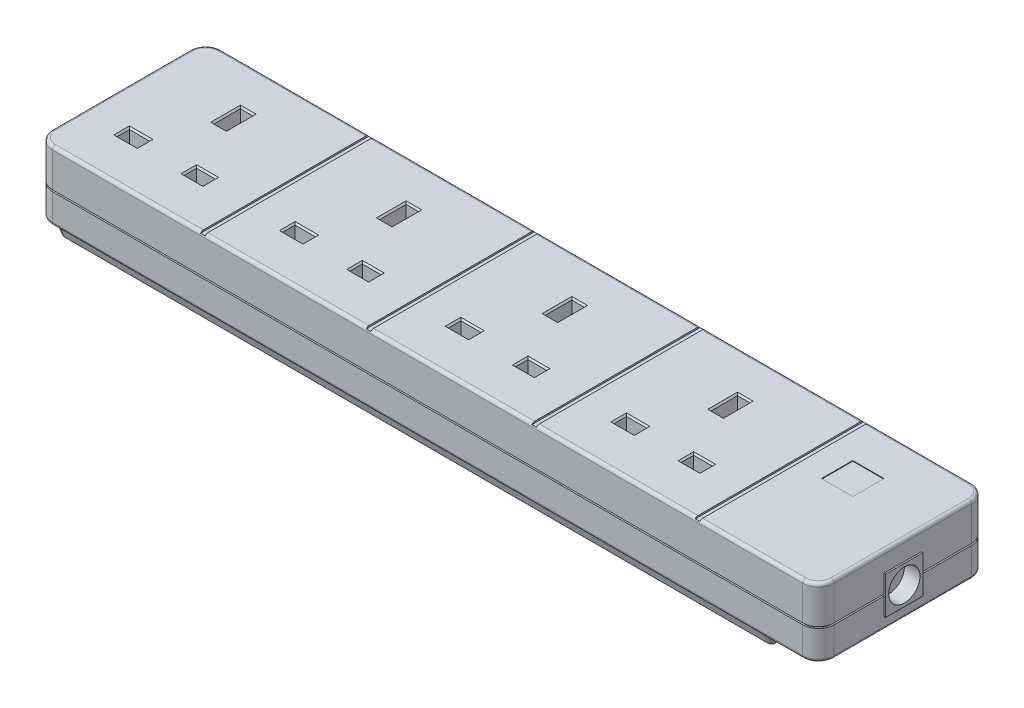
from build123d import *

# Parameters (mm, degrees)
BOSS_EXTRUDE1_DEPTH        = 12
BOSS_EXTRUDE2_DEPTH        = 0.5
BOSS_EXTRUDE3_DEPTH        = 9.5
BOSS_EXTRUDE4_DEPTH        = 5
BOSS_EXTRUDE4_TAPER        = 20
FILLET1_R                  = 1
SKETCH5_W                  = 1.5
SKETCH5_H                  = 54
CUT_EXTRUDE1_DEPTH         = 0.5
SKETCH6_W                  = 10
SKETCH6_H                  = 10
CUT_EXTRUDE2_DEPTH         = 2
SKETCH7_W                  = 8
SKETCH7_H                  = 8
CUT_EXTRUDE3_DEPTH         = 10
SKETCH8_W                  = 9.8
SKETCH8_H                  = 9.8
BOSS_EXTRUDE5_DEPTH        = 1.9
SKETCH9_W                  = 4
SKETCH9_H                  = 8.5
SKETCH9_W_2                = 6.5
SKETCH9_H_2                = 4
SKETCH9_W_3                = 6
CUT_EXTRUDE4_DEPTH         = 10
CHAMFER1_SIZE              = 0.5
LPATTERN1_COUNT            = 4
LPATTERN1_PITCH            = 53
CHAMFER1_OF_LPATTERN1_SIZE = 0.5
SKETCH10_W                 = 12
SKETCH10_H                 = 12
SKETCH10_R                 = 5
BOSS_EXTRUDE6_DEPTH        = 0.5
BOSS_EXTRUDE6_DEPTH_BACK   = 5
SKETCH11_R                 = 5
CUT_EXTRUDE5_DEPTH         = 5
CUT_EXTRUDE6_DEPTH         = 5
CUT_EXTRUDE7_DEPTH         = 3.5


with BuildPart() as part:
    # Sketch1 → Boss-Extrude1 (new body)
    with BuildSketch(Plane(origin=(0, 0, 0), x_dir=(1, 0, 0), z_dir=(0, 1, 0))):
        with BuildLine():
            Line((-120, 27), (120, 27))
            ThreePointArc((120, 27), (123.535533906, 25.535533906), (125, 22))
            Line((125, 22), (125, -22))
            ThreePointArc((125, -22), (123.535533906, -25.535533906), (120, -27))
            Line((120, -27), (-120, -27))
            ThreePointArc((-120, -27), (-123.535533906, -25.535533906), (-125, -22))
            Line((-125, -22), (-125, 22))
            ThreePointArc((-125, 22), (-123.535533906, 25.535533906), (-120, 27))
        make_face()
    extrude(amount=-BOSS_EXTRUDE1_DEPTH)

    # Sketch2 → Boss-Extrude2 (add)
    with BuildSketch(Plane.XZ.offset(12)):
        with BuildLine():
            Line((120, 26.5), (-120, 26.5))
            ThreePointArc((-120, 26.5), (-123.181980515, 25.181980515), (-124.5, 22))
            Line((-124.5, 22), (-124.5, -22))
            ThreePointArc((-124.5, -22), (-123.181980515, -25.181980515), (-120, -26.5))
            Line((-120, -26.5), (120, -26.5))
            ThreePointArc((120, -26.5), (123.181980515, -25.181980515), (124.5, -22))
            Line((124.5, -22), (124.5, 22))
            ThreePointArc((124.5, 22), (123.181980515, 25.181980515), (120, 26.5))
        make_face()
    extrude(amount=BOSS_EXTRUDE2_DEPTH)

    # Sketch3 → Boss-Extrude3 (add)
    with BuildSketch(Plane.XZ.offset(12.5)):
        with BuildLine():
            Line((125, 22), (125, -22))
            ThreePointArc((125, -22), (123.535533906, -25.535533906), (120, -27))
            Line((120, -27), (-120, -27))
            ThreePointArc((-120, -27), (-123.535533906, -25.535533906), (-125, -22))
            Line((-125, -22), (-125, 22))
            ThreePointArc((-125, 22), (-123.535533906, 25.535533906), (-120, 27))
            Line((-120, 27), (120, 27))
            ThreePointArc((120, 27), (123.535533906, 25.535533906), (125, 22))
        make_face()
    extrude(amount=BOSS_EXTRUDE3_DEPTH)

    # Sketch4 → Boss-Extrude4 (add)
    with BuildSketch(Plane.XZ.offset(22)):
        with BuildLine():
            Line((108, -22), (108, 22))
            ThreePointArc((108, 22), (107.121320344, 24.121320344), (105, 25))
            Line((105, 25), (-120, 25))
            ThreePointArc((-120, 25), (-122.121320344, 24.121320344), (-123, 22))
            Line((-123, 22), (-123, -22))
            ThreePointArc((-123, -22), (-122.121320344, -24.121320344), (-120, -25))
            Line((-120, -25), (105, -25))
            ThreePointArc((105, -25), (107.121320344, -24.121320344), (108, -22))
        make_face()
    extrude(amount=BOSS_EXTRUDE4_DEPTH, taper=BOSS_EXTRUDE4_TAPER)

    # Fillet1
    fillet1_edges = [part.edges().sort_by_distance(p)[0] for p in [
        (0, 0, -27),
        (123.535533906, 0, -25.535533906),
        (125, 0, 0),
        (123.535533906, 0, 25.535533906),
        (123.535533906, -22, -25.535533906),
        (125, -22, 0),
        (123.535533906, -22, 25.535533906),
        (0, -22, 27),
        (-123.535533906, -22, 25.535533906),
        (-125, -22, 0),
        (-123.535533906, -22, -25.535533906),
        (0, -22, -27),
        (0, 0, 27),
        (-123.535533906, 0, 25.535533906),
        (-125, 0, 0),
        (-123.535533906, 0, -25.535533906),
    ]]
    fillet(fillet1_edges, radius=FILLET1_R)

    # Sketch5 → Cut-Extrude1 (cut)
    with BuildSketch(Plane(origin=(0, 0, 0), x_dir=(1, 0, 0), z_dir=(0, 1, 0))):
        with Locations((-72, 0)):
            Rectangle(SKETCH5_W, SKETCH5_H)
        with Locations((-19, 0)):
            Rectangle(SKETCH5_W, SKETCH5_H)
        with Locations((34, 0)):
            Rectangle(SKETCH5_W, SKETCH5_H)
        with Locations((86.25, 0)):
            Rectangle(SKETCH5_W, SKETCH5_H)
    extrude(amount=-CUT_EXTRUDE1_DEPTH, mode=Mode.SUBTRACT)

    # Sketch6 → Cut-Extrude2 (cut)
    with BuildSketch(Plane(origin=(0, 0, 0), x_dir=(1, 0, 0), z_dir=(0, 1, 0))):
        with Locations((100, 9)):
            Rectangle(SKETCH6_W, SKETCH6_H)
    extrude(amount=-CUT_EXTRUDE2_DEPTH, mode=Mode.SUBTRACT)

    # Sketch7 → Cut-Extrude3 (cut)
    with BuildSketch(Plane(origin=(0, -2, 0), x_dir=(1, 0, 0), z_dir=(0, 1, 0))):
        with Locations((100, 9)):
            Rectangle(SKETCH7_W, SKETCH7_H)
    extrude(amount=-CUT_EXTRUDE3_DEPTH, mode=Mode.SUBTRACT)

    # Sketch9 → Cut-Extrude4 (cut)
    with BuildSketch(Plane(origin=(0, 0, 0), x_dir=(1, 0, 0), z_dir=(0, 1, 0))):
        with Locations((60.125, 9.75)):
            Rectangle(SKETCH9_W, SKETCH9_H)
        with Locations((49.375, -11.5)):
            Rectangle(SKETCH9_W_2, SKETCH9_H_2)
        with Locations((70.625, -11.5)):
            Rectangle(SKETCH9_W_3, SKETCH9_H_2)
    cut_extrude4 = extrude(amount=-CUT_EXTRUDE4_DEPTH, mode=Mode.SUBTRACT)

    # Chamfer1
    chamfer1_edges = [part.edges().sort_by_distance(p)[0] for p in [
        (58.125, 0, -9.75),
        (60.125, 0, -5.5),
        (62.125, 0, -9.75),
        (60.125, 0, -14),
        (46.125, 0, 11.5),
        (49.375, 0, 13.5),
        (52.625, 0, 11.5),
        (49.375, 0, 9.5),
        (67.625, 0, 11.5),
        (70.625, 0, 13.5),
        (73.625, 0, 11.5),
        (70.625, 0, 9.5),
    ]]
    chamfer(chamfer1_edges, length=CHAMFER1_SIZE)

    # LPattern1: Cut-Extrude4 ×4
    with Locations(*[(-i * LPATTERN1_PITCH, 0, 0) for i in range(1, LPATTERN1_COUNT)]):
        add(cut_extrude4, mode=Mode.SUBTRACT)

    # Chamfer1 of LPattern1
    chamfer1_of_lpattern1_edges = [part.edges().sort_by_distance(p)[0] for p in [
        (5.125, 0, -9.75),
        (7.125, 0, -5.5),
        (9.125, 0, -9.75),
        (7.125, 0, -14),
        (-6.875, 0, 11.5),
        (-3.625, 0, 13.5),
        (-0.375, 0, 11.5),
        (-3.625, 0, 9.5),
        (14.625, 0, 11.5),
        (17.625, 0, 13.5),
        (20.625, 0, 11.5),
        (17.625, 0, 9.5),
        (-47.875, 0, -9.75),
        (-45.875, 0, -5.5),
        (-43.875, 0, -9.75),
        (-45.875, 0, -14),
        (-59.875, 0, 11.5),
        (-56.625, 0, 13.5),
        (-53.375, 0, 11.5),
        (-56.625, 0, 9.5),
        (-38.375, 0, 11.5),
        (-35.375, 0, 13.5),
        (-32.375, 0, 11.5),
        (-35.375, 0, 9.5),
        (-100.875, 0, -9.75),
        (-98.875, 0, -5.5),
        (-96.875, 0, -9.75),
        (-98.875, 0, -14),
        (-112.875, 0, 11.5),
        (-109.625, 0, 13.5),
        (-106.375, 0, 11.5),
        (-109.625, 0, 9.5),
        (-91.375, 0, 11.5),
        (-88.375, 0, 13.5),
        (-85.375, 0, 11.5),
        (-88.375, 0, 9.5),
    ]]
    chamfer(chamfer1_of_lpattern1_edges, length=CHAMFER1_OF_LPATTERN1_SIZE)

    # Sketch10 → Boss-Extrude6 (add, two sides)
    with BuildSketch(Plane(origin=(125, 0, 0), x_dir=(0, 0, -1), z_dir=(1, 0, 0))) as boss_extrude6_sk:
        with Locations((0, -12.25)):
            Rectangle(SKETCH10_W, SKETCH10_H)
        with Locations((0, -12.25)):
            Circle(SKETCH10_R, mode=Mode.SUBTRACT)
    extrude(amount=BOSS_EXTRUDE6_DEPTH)
    extrude(boss_extrude6_sk.sketch, amount=-BOSS_EXTRUDE6_DEPTH_BACK)

    # Sketch11 → Cut-Extrude5 (cut)
    with BuildSketch(Plane(origin=(125.5, 0, 0), x_dir=(0, 0, -1), z_dir=(1, 0, 0))):
        with Locations((0, -12.25)):
            Circle(SKETCH11_R)
    extrude(amount=-CUT_EXTRUDE5_DEPTH, mode=Mode.SUBTRACT)

    # Sketch12 → Cut-Extrude6 (cut)
    with BuildSketch(Plane.XZ.offset(27)):
        with BuildLine():
            Line((-77.5, -5.436931771), (-77.5, -9))
            ThreePointArc((-77.5, -9), (-80, -11.5), (-82.5, -9))
            Line((-82.5, -9), (-82.5, -5.436931771))
            ThreePointArc((-82.5, -5.436931771), (-80, 2.25), (-77.5, -5.436931771))
        make_face()
        with BuildLine():
            Line((71.5, -9), (71.5, -5.436931771))
            ThreePointArc((71.5, -5.436931771), (74, 2.25), (76.5, -5.436931771))
            Line((76.5, -5.436931771), (76.5, -9))
            ThreePointArc((76.5, -9), (74, -11.5), (71.5, -9))
        make_face()
    extrude(amount=-CUT_EXTRUDE6_DEPTH, mode=Mode.SUBTRACT)

    # Sketch13 → Cut-Extrude7 (cut)
    with BuildSketch(Plane.XZ.offset(22)):
        with BuildLine():
            Line((-75.75, -2), (-75.75, -9))
            ThreePointArc((-75.75, -9), (-80, -13.25), (-84.25, -9))
            Line((-84.25, -9), (-84.25, -2))
            ThreePointArc((-84.25, -2), (-80, 2.25), (-75.75, -2))
        make_face()
        with BuildLine():
            Line((78.25, -2), (78.25, -9))
            ThreePointArc((78.25, -9), (74, -13.25), (69.75, -9))
            Line((69.75, -9), (69.75, -2))
            ThreePointArc((69.75, -2), (74, 2.25), (78.25, -2))
        make_face()
    extrude(amount=CUT_EXTRUDE7_DEPTH, mode=Mode.SUBTRACT)


with BuildPart() as body_2:
    # Sketch8 → Boss-Extrude5 (new body)
    with BuildSketch(Plane(origin=(0, -2, 0), x_dir=(1, 0, 0), z_dir=(0, 1, 0))):
        with Locations((100, 9)):
            Rectangle(SKETCH8_W, SKETCH8_H)
    extrude(amount=BOSS_EXTRUDE5_DEPTH)


solid = Compound([part.part, body_2.part])
